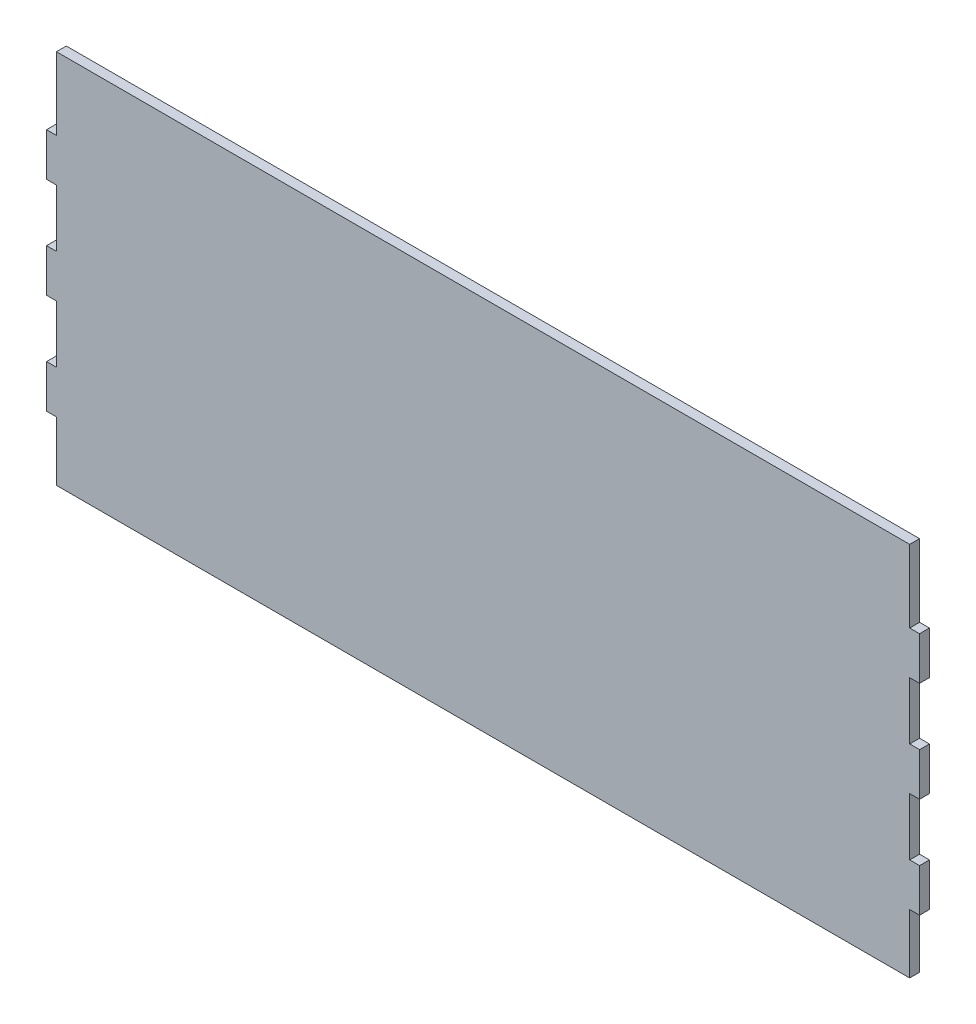
from build123d import *

# Parameters (mm, degrees)
CROQUIS1_W              = 265
CROQUIS1_H              = 110
SALIENTE_EXTRUIR1_DEPTH = 3
CROQUIS2_W              = 3
CROQUIS2_H              = 17.427708433
CORTAR_EXTRUIR1_DEPTH   = 3
CROQUIS4_W              = 259
CROQUIS4_H              = 4
SALIENTE_EXTRUIR3_DEPTH = 3


with BuildPart() as part:
    # Croquis1 → Saliente-Extruir1 (new body)
    with BuildSketch(Plane.XY):
        Rectangle(CROQUIS1_W, CROQUIS1_H)
    extrude(amount=SALIENTE_EXTRUIR1_DEPTH)

    # Croquis2 → Cortar-Extruir1 (cut)
    with BuildSketch(Plane.XY.offset(3)):
        Polygon((-132.5, 55), (-132.5, 37), (-129.5, 37), (-129.5, 52), (-129.5, 55), align=None)
        with Locations((-131, 15.237951406)):
            Rectangle(CROQUIS2_W, CROQUIS2_H)
        Polygon((129.5, 55), (129.5, 52), (129.5, 37), (132.5, 37), (132.5, 55), align=None)
        with Locations((131, 15.237951406)):
            Rectangle(CROQUIS2_W, CROQUIS2_H)
        with Locations((131, -15.237951406)):
            Rectangle(CROQUIS2_W, CROQUIS2_H)
        Polygon((129.5, -37), (129.5, -52), (129.5, -55), (132.5, -55), (132.5, -37), align=None)
        with Locations((-131, -15.237951406)):
            Rectangle(CROQUIS2_W, CROQUIS2_H)
        Polygon((-129.5, -37), (-132.5, -37), (-132.5, -55), (-129.5, -55), (-129.5, -52), align=None)
    extrude(amount=-CORTAR_EXTRUIR1_DEPTH, mode=Mode.SUBTRACT)

    # Croquis4 → Saliente-Extruir3 (add)
    with BuildSketch(Plane(origin=(0, 0, 0), x_dir=(-1, 0, 0), z_dir=(0, 0, -1))):
        with Locations((0, 57)):
            Rectangle(CROQUIS4_W, CROQUIS4_H)
    extrude(amount=-SALIENTE_EXTRUIR3_DEPTH)


solid = part.part
